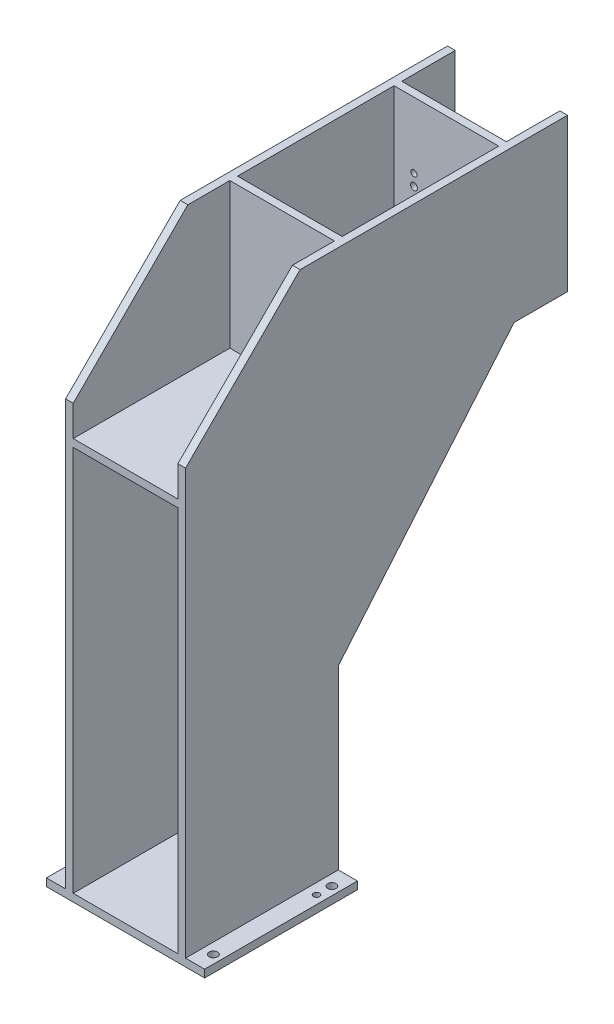
from build123d import *

# Parameters (mm, degrees)
BOSS_EXTRUDE1_DEPTH      = 10
BOSS_EXTRUDE1_DEPTH_BACK = 147
SKETCH3_W                = 137
SKETCH3_H                = 500
CUT_EXTRUDE1_DEPTH       = 705.5
SKETCH4_W                = 137
SKETCH4_H                = 200
BOSS_EXTRUDE2_DEPTH      = 10
CUT_EXTRUDE3_REACH       = 82
SKETCH6_R                = 4.5
SKETCH6_R_2              = 8
SKETCH6_R_3              = 4
SKETCH9_W                = 25
SKETCH9_H                = 200
BOSS_EXTRUDE4_DEPTH      = 10
SKETCH10_R               = 5.5
SKETCH10_R_2             = 4
CUT_EXTRUDE4_DEPTH       = 716.5
SKETCH11_W               = 137
SKETCH11_H               = 430
BOSS_EXTRUDE5_DEPTH      = 10
SKETCH12_W               = 10
SKETCH12_H               = 200
BOSS_EXTRUDE6_DEPTH      = 137


with BuildPart() as part:
    # Sketch1 → Boss-Extrude1 (new body, two sides)
    with BuildSketch(Plane(origin=(0, 0, 0), x_dir=(0, 0, -1), z_dir=(1, 0, 0))) as boss_extrude1_sk:
        Polygon((200, 515.5), (200, 241.396673703), (430, 515.5), align=None)
        Polygon((200, 0), (200, 515.5), (500, 515.5), (500, 715.5), (150, 715.5), (0, 565.5), (0, 0), align=None)
    extrude(amount=BOSS_EXTRUDE1_DEPTH)
    extrude(boss_extrude1_sk.sketch, amount=-BOSS_EXTRUDE1_DEPTH_BACK)

    # Sketch3 → Cut-Extrude1 (cut)
    with BuildSketch(Plane(origin=(0, 715.5, 0), x_dir=(1, 0, 0), z_dir=(0, 1, 0))):
        with Locations((-68.5, 250)):
            Rectangle(SKETCH3_W, SKETCH3_H)
    extrude(amount=-CUT_EXTRUDE1_DEPTH, mode=Mode.SUBTRACT)

    # Sketch4 → Boss-Extrude2 (add)
    with BuildSketch(Plane(origin=(0, 0, -430), x_dir=(-1, 0, 0), z_dir=(0, 0, -1))):
        with Locations((68.5, 615.5)):
            Rectangle(SKETCH4_W, SKETCH4_H)
    extrude(amount=-BOSS_EXTRUDE2_DEPTH)

    # Sketch6 → Cut-Extrude3 (cut, up to next)
    with BuildSketch(Plane.XY.offset(-420), mode=Mode.PRIVATE) as cut_extrude3_sk1:
        with Locations((-111, 567.7)):
            Circle(SKETCH6_R)
    cut_extrude3_tool1 = extrude(cut_extrude3_sk1.sketch, amount=-CUT_EXTRUDE3_REACH, mode=Mode.PRIVATE) & part.part
    add(cut_extrude3_tool1.solids().sort_by_distance((-111, 567.7, -420))[0], mode=Mode.SUBTRACT)
    # Sketch6 → Cut-Extrude3 (cut, up to next)
    with BuildSketch(Plane.XY.offset(-420), mode=Mode.PRIVATE) as cut_extrude3_sk2:
        with Locations((-26, 567.7)):
            Circle(SKETCH6_R)
    cut_extrude3_tool2 = extrude(cut_extrude3_sk2.sketch, amount=-CUT_EXTRUDE3_REACH, mode=Mode.PRIVATE) & part.part
    add(cut_extrude3_tool2.solids().sort_by_distance((-26, 567.7, -420))[0], mode=Mode.SUBTRACT)
    # Sketch6 → Cut-Extrude3 (cut, up to next)
    with BuildSketch(Plane.XY.offset(-420), mode=Mode.PRIVATE) as cut_extrude3_sk3:
        with Locations((-111, 614.2)):
            Circle(SKETCH6_R)
    cut_extrude3_tool3 = extrude(cut_extrude3_sk3.sketch, amount=-CUT_EXTRUDE3_REACH, mode=Mode.PRIVATE) & part.part
    add(cut_extrude3_tool3.solids().sort_by_distance((-111, 614.2, -420))[0], mode=Mode.SUBTRACT)
    # Sketch6 → Cut-Extrude3 (cut, up to next)
    with BuildSketch(Plane.XY.offset(-420), mode=Mode.PRIVATE) as cut_extrude3_sk4:
        with Locations((-26, 614.2)):
            Circle(SKETCH6_R)
    cut_extrude3_tool4 = extrude(cut_extrude3_sk4.sketch, amount=-CUT_EXTRUDE3_REACH, mode=Mode.PRIVATE) & part.part
    add(cut_extrude3_tool4.solids().sort_by_distance((-26, 614.2, -420))[0], mode=Mode.SUBTRACT)
    # Sketch6 → Cut-Extrude3 (cut, up to next)
    with BuildSketch(Plane.XY.offset(-420), mode=Mode.PRIVATE) as cut_extrude3_sk5:
        with Locations((-63, 609)):
            Circle(SKETCH6_R_2)
    cut_extrude3_tool5 = extrude(cut_extrude3_sk5.sketch, amount=-CUT_EXTRUDE3_REACH, mode=Mode.PRIVATE) & part.part
    add(cut_extrude3_tool5.solids().sort_by_distance((-63, 609, -420))[0], mode=Mode.SUBTRACT)
    # Sketch6 → Cut-Extrude3 (cut, up to next)
    with BuildSketch(Plane.XY.offset(-420), mode=Mode.PRIVATE) as cut_extrude3_sk6:
        with Locations((-111, 629.2)):
            Circle(SKETCH6_R_3)
    cut_extrude3_tool6 = extrude(cut_extrude3_sk6.sketch, amount=-CUT_EXTRUDE3_REACH, mode=Mode.PRIVATE) & part.part
    add(cut_extrude3_tool6.solids().sort_by_distance((-111, 629.2, -420))[0], mode=Mode.SUBTRACT)
    # Sketch6 → Cut-Extrude3 (cut, up to next)
    with BuildSketch(Plane.XY.offset(-420), mode=Mode.PRIVATE) as cut_extrude3_sk7:
        with Locations((-26, 552.7)):
            Circle(SKETCH6_R_3)
    cut_extrude3_tool7 = extrude(cut_extrude3_sk7.sketch, amount=-CUT_EXTRUDE3_REACH, mode=Mode.PRIVATE) & part.part
    add(cut_extrude3_tool7.solids().sort_by_distance((-26, 552.7, -420))[0], mode=Mode.SUBTRACT)
    # Sketch6 → Cut-Extrude3 (cut, up to next)
    with BuildSketch(Plane.XY.offset(-420), mode=Mode.PRIVATE) as cut_extrude3_sk8:
        with Locations((-111, 590.7)):
            Circle(SKETCH6_R)
    cut_extrude3_tool8 = extrude(cut_extrude3_sk8.sketch, amount=-CUT_EXTRUDE3_REACH, mode=Mode.PRIVATE) & part.part
    add(cut_extrude3_tool8.solids().sort_by_distance((-111, 590.7, -420))[0], mode=Mode.SUBTRACT)
    # Sketch6 → Cut-Extrude3 (cut, up to next)
    with BuildSketch(Plane.XY.offset(-420), mode=Mode.PRIVATE) as cut_extrude3_sk9:
        with Locations((-26, 590.7)):
            Circle(SKETCH6_R)
    cut_extrude3_tool9 = extrude(cut_extrude3_sk9.sketch, amount=-CUT_EXTRUDE3_REACH, mode=Mode.PRIVATE) & part.part
    add(cut_extrude3_tool9.solids().sort_by_distance((-26, 590.7, -420))[0], mode=Mode.SUBTRACT)

    # Sketch9 → Boss-Extrude4 (add)
    with BuildSketch(Plane.XZ):
        with Locations((-159.5, -100)):
            Rectangle(SKETCH9_W, SKETCH9_H)
        with Locations((22.5, -100)):
            Rectangle(SKETCH9_W, SKETCH9_H)
    extrude(amount=-BOSS_EXTRUDE4_DEPTH)

    # Sketch10 → Cut-Extrude4 (cut, through all)
    with BuildSketch(Plane.XZ):
        with Locations((-161, -22.5)):
            Circle(SKETCH10_R)
        with Locations((24, -22.5)):
            Circle(SKETCH10_R)
        with Locations((24, -177.5)):
            Circle(SKETCH10_R)
        with Locations((-161, -177.5)):
            Circle(SKETCH10_R)
        with Locations((-161, -42.5)):
            Circle(SKETCH10_R_2)
        with Locations((24, -157.5)):
            Circle(SKETCH10_R_2)
    extrude(amount=-CUT_EXTRUDE4_DEPTH, mode=Mode.SUBTRACT)

    # Sketch11 → Boss-Extrude5 (add)
    with BuildSketch(Plane.XZ.offset(-515.5)):
        with Locations((-68.5, -215)):
            Rectangle(SKETCH11_W, SKETCH11_H)
    extrude(amount=-BOSS_EXTRUDE5_DEPTH)

    # Sketch12 → Boss-Extrude6 (add)
    with BuildSketch(Plane(origin=(-137, 0, 0), x_dir=(0, 0, -1), z_dir=(1, 0, 0))):
        with Locations((210, 615.5)):
            Rectangle(SKETCH12_W, SKETCH12_H)
    extrude(amount=BOSS_EXTRUDE6_DEPTH)


solid = part.part
